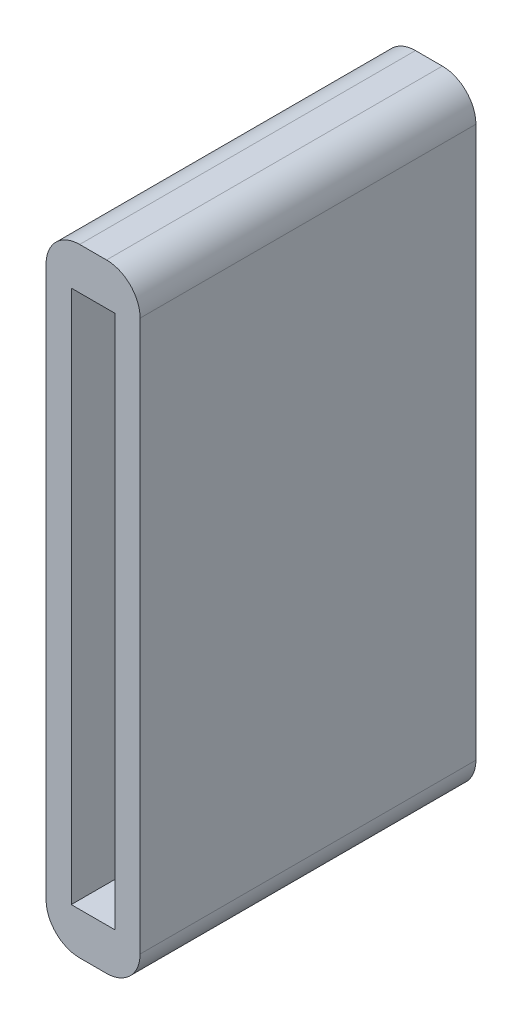
from build123d import *

# Parameters (mm, degrees)
ESQUISSE1_W        = 5.6
ESQUISSE1_H        = 36.8
ESQUISSE1_W_2      = 2.6
ESQUISSE1_H_2      = 31.8
BOSS_EXTRU_1_DEPTH = 20
CONG_1_R           = 2


with BuildPart() as part:
    # Esquisse1 → Boss.-Extru.1 (new body)
    with BuildSketch(Plane.XY):
        with Locations((0.188649611, -11.438461538)):
            Rectangle(ESQUISSE1_W, ESQUISSE1_H)
        with Locations((0.188649611, -11.438461538)):
            Rectangle(ESQUISSE1_W_2, ESQUISSE1_H_2, mode=Mode.SUBTRACT)
    extrude(amount=BOSS_EXTRU_1_DEPTH)

    # Congé1
    cong_1_edges = [part.edges().sort_by_distance(p)[0] for p in [
        (-2.611350389, 6.961538462, 10),
        (2.988649611, 6.961538462, 10),
        (2.988649611, -29.838461538, 10),
        (-2.611350389, -29.838461538, 10),
    ]]
    fillet(cong_1_edges, radius=CONG_1_R)


solid = part.part
